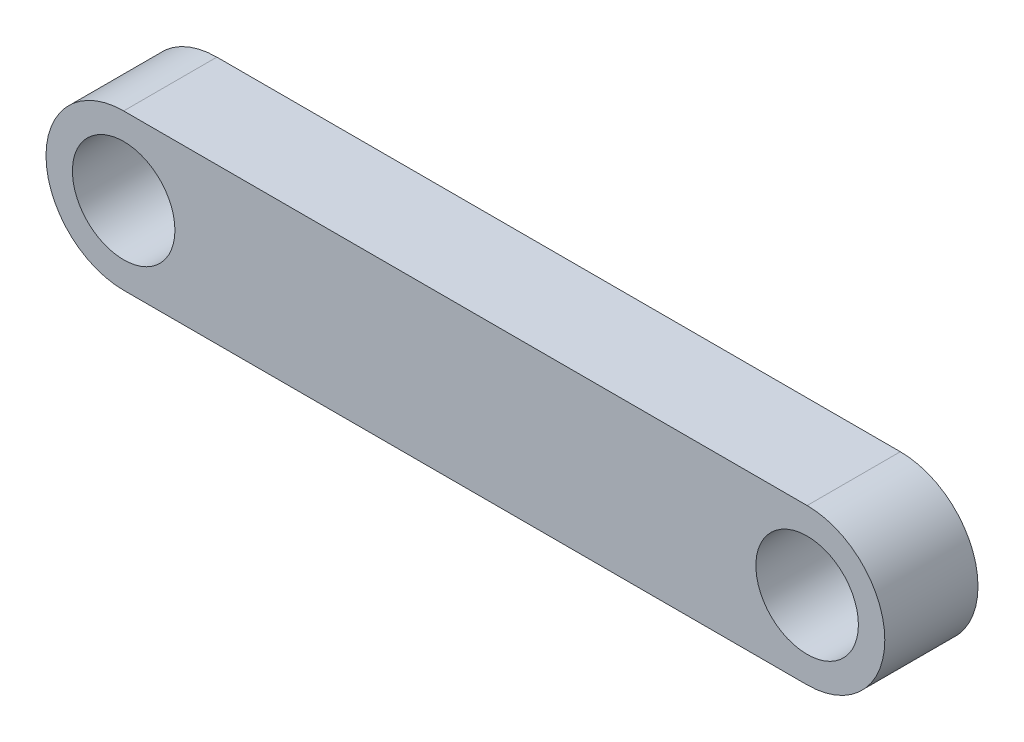
from build123d import *

# Parameters (mm, degrees)
SKETCH1_R           = 1.65
BOSS_EXTRUDE1_DEPTH = 3


with BuildPart() as part:
    # Sketch1 → Boss-Extrude1 (new body)
    with BuildSketch(Plane.XY):
        with BuildLine():
            Line((0, 2.5), (22, 2.5))
            ThreePointArc((22, 2.5), (24.5, 0), (22, -2.5))
            Line((22, -2.5), (0, -2.5))
            ThreePointArc((0, -2.5), (-2.5, 0), (0, 2.5))
        make_face()
        Circle(SKETCH1_R, mode=Mode.SUBTRACT)
        with Locations((22, 0)):
            Circle(SKETCH1_R, mode=Mode.SUBTRACT)
    extrude(amount=BOSS_EXTRUDE1_DEPTH)


solid = part.part
